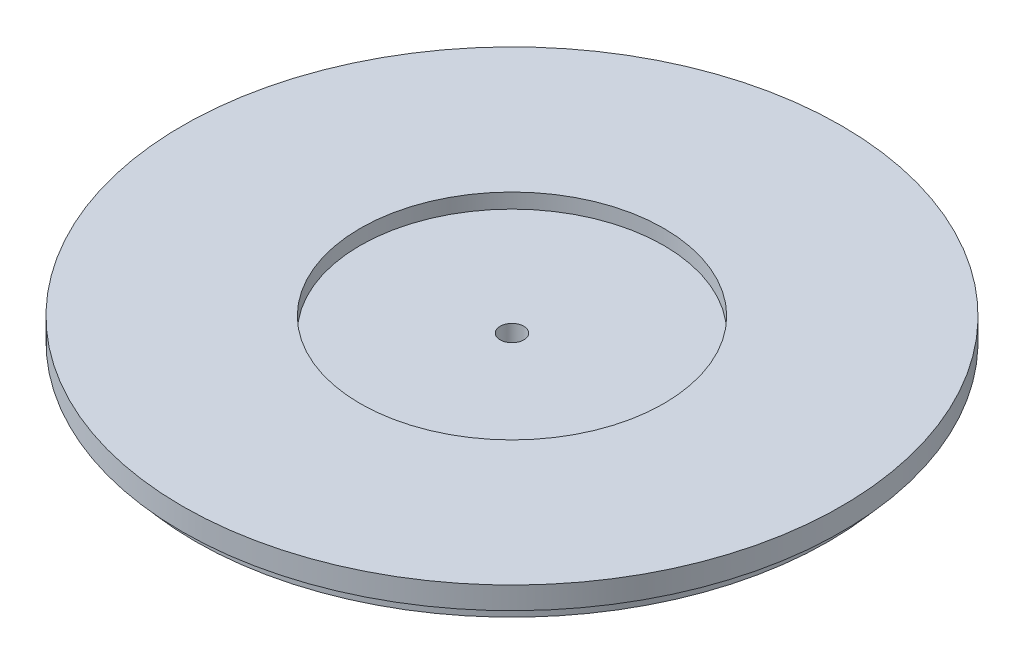
from build123d import *


with BuildPart() as part:
    # Skizze2 → Rotation1 (revolve)
    with BuildSketch(Plane.XY):
        Polygon((-1.6, 0), (-1.6, 3), (-20.5, 3), (-20.5, 5), (-44.5, 5), (-44.5, 2), (-42.75, 2), (-42.75, 0), align=None)
    revolve(axis=Axis((0, -1.741466568, 0), (0, 1, 0)))


solid = part.part
